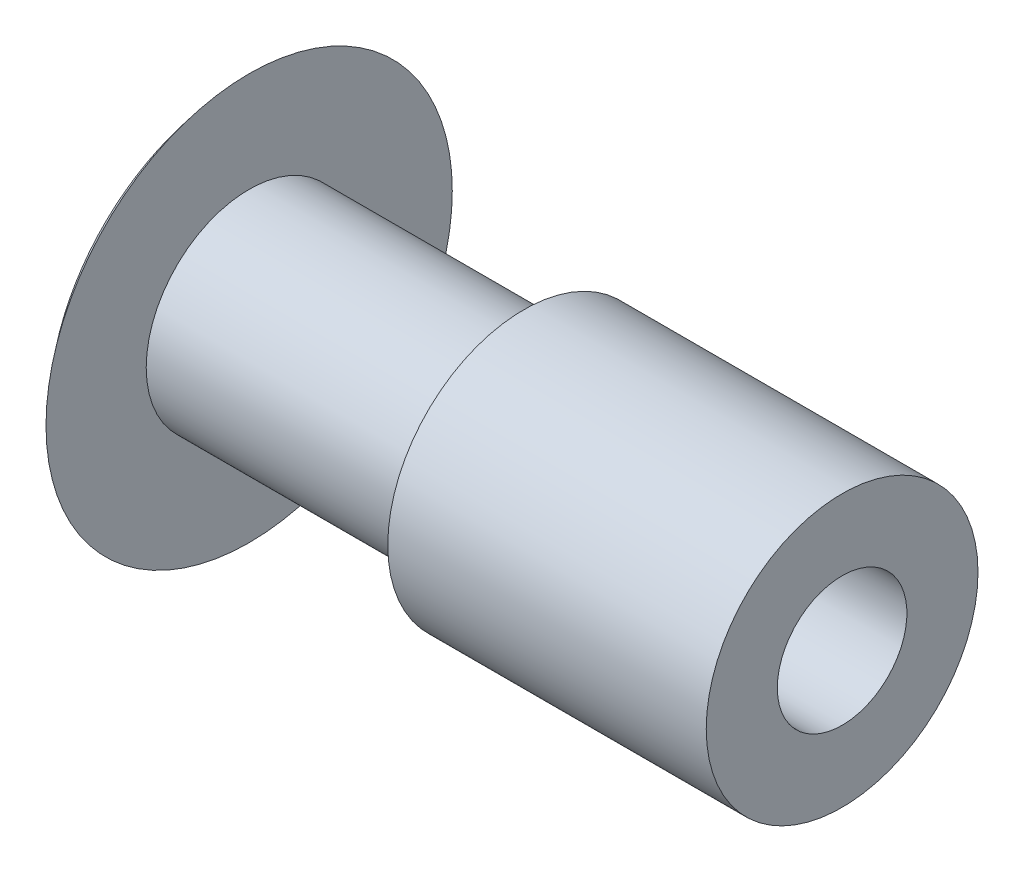
from build123d import *

# Parameters (mm, degrees)
SKETCH2_R         = 1.4986
CENTER_HOLE_DEPTH = 16.24


with BuildPart() as part:
    # Sketch1 → Revolve1 (revolve)
    with BuildSketch(Plane(origin=(0, 0, 0), x_dir=(1, 0, 0), z_dir=(0, 1, 0))):
        Polygon((0, 0), (0, 4.699), (1.524, 4.699), (1.524, 2.38125), (7.874, 2.38125), (7.874, 3.14325), (15.24, 3.14325), (15.24, 0), align=None)
    revolve(axis=Axis((15.24, 0, 0), (-1, 0, 0)))

    # Sketch2 → Center-Hole (cut, through all)
    with BuildSketch(Plane.ZY):
        Circle(SKETCH2_R)
    extrude(amount=-CENTER_HOLE_DEPTH, mode=Mode.SUBTRACT)

    # Sketch3 → Cut-Revolve1 (revolve, cut)
    with BuildSketch(Plane(origin=(0, 0, 0), x_dir=(1, 0, 0), z_dir=(0, 1, 0))):
        with BuildLine():
            Line((1.524, 4.699), (0, 4.699))
            Line((0, 4.699), (0, 1.4986))
            ThreePointArc((0, 1.4986), (0.548299529, 3.200562129), (1.524, 4.699))
        make_face()
    revolve(axis=Axis((0, 0, 0), (1, 0, 0)), mode=Mode.SUBTRACT)


solid = part.part
